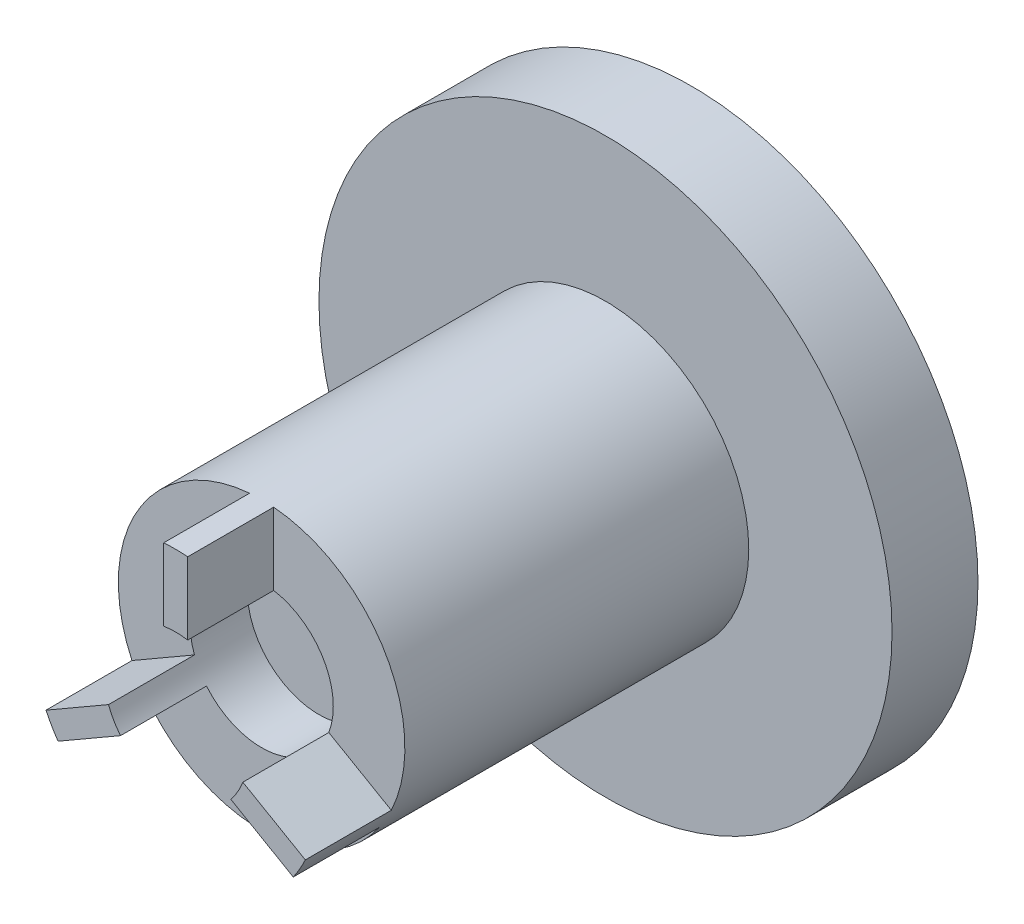
from build123d import *

# Parameters (mm, degrees)
SKETCH16_R          = 10
BOSS_EXTRUDE4_DEPTH = 1.5
SKETCH17_R          = 5
BOSS_EXTRUDE5_DEPTH = 15
SKETCH18_R          = 2.5
CUT_EXTRUDE4_DEPTH  = 5
CUT_EXTRUDE7_DEPTH  = 3


with BuildPart() as part:
    # Sketch16 → Boss-Extrude4 (new body, symmetric)
    with BuildSketch(Plane.XY):
        Circle(SKETCH16_R)
    extrude(amount=BOSS_EXTRUDE4_DEPTH, both=True)

    # Sketch17 → Boss-Extrude5 (add)
    with BuildSketch(Plane.XY.offset(1.5)):
        Circle(SKETCH17_R)
    extrude(amount=BOSS_EXTRUDE5_DEPTH)

    # Sketch18 → Cut-Extrude4 (cut)
    with BuildSketch(Plane.XY.offset(16.5)):
        Circle(SKETCH18_R)
    extrude(amount=-CUT_EXTRUDE4_DEPTH, mode=Mode.SUBTRACT)

    # Sketch19 → Cut-Extrude7 (cut)
    with BuildSketch(Plane.XY.offset(16.5)):
        with BuildLine():
            ThreePointArc((-2.344526361, -0.867868735), (-2.165063509, 1.25), (-0.420666809, 2.464353756))
            Line((-0.420666809, 2.464353756), (-0.420666809, 4.982272517))
            ThreePointArc((-0.420666809, 4.982272517), (-4.330127019, 2.5), (-4.525107973, -2.126828116))
            Line((-4.525107973, -2.126828116), (-2.344526361, -0.867868735))
        make_face()
        with BuildLine():
            Line((0.420666809, 4.982272517), (0.420666809, 2.464353756))
            ThreePointArc((0.420666809, 2.464353756), (1.910715445, 1.612193068), (2.5, 0))
            ThreePointArc((2.5, 0), (2.460824649, -0.44084243), (2.344526361, -0.867868735))
            Line((2.344526361, -0.867868735), (4.525107973, -2.126828116))
            ThreePointArc((4.525107973, -2.126828116), (4.879832982, -1.089600875), (5, 0))
            ThreePointArc((5, 0), (3.681258891, 3.383538529), (0.420666809, 4.982272517))
        make_face()
        with BuildLine():
            Line((4.104441164, -2.855444402), (1.923859552, -1.596485021))
            ThreePointArc((1.923859552, -1.596485021), (0, -2.5), (-1.923859552, -1.596485021))
            Line((-1.923859552, -1.596485021), (-4.104441164, -2.855444402))
            ThreePointArc((-4.104441164, -2.855444402), (0, -5), (4.104441164, -2.855444402))
        make_face()
    extrude(amount=-CUT_EXTRUDE7_DEPTH, mode=Mode.SUBTRACT)


solid = part.part
